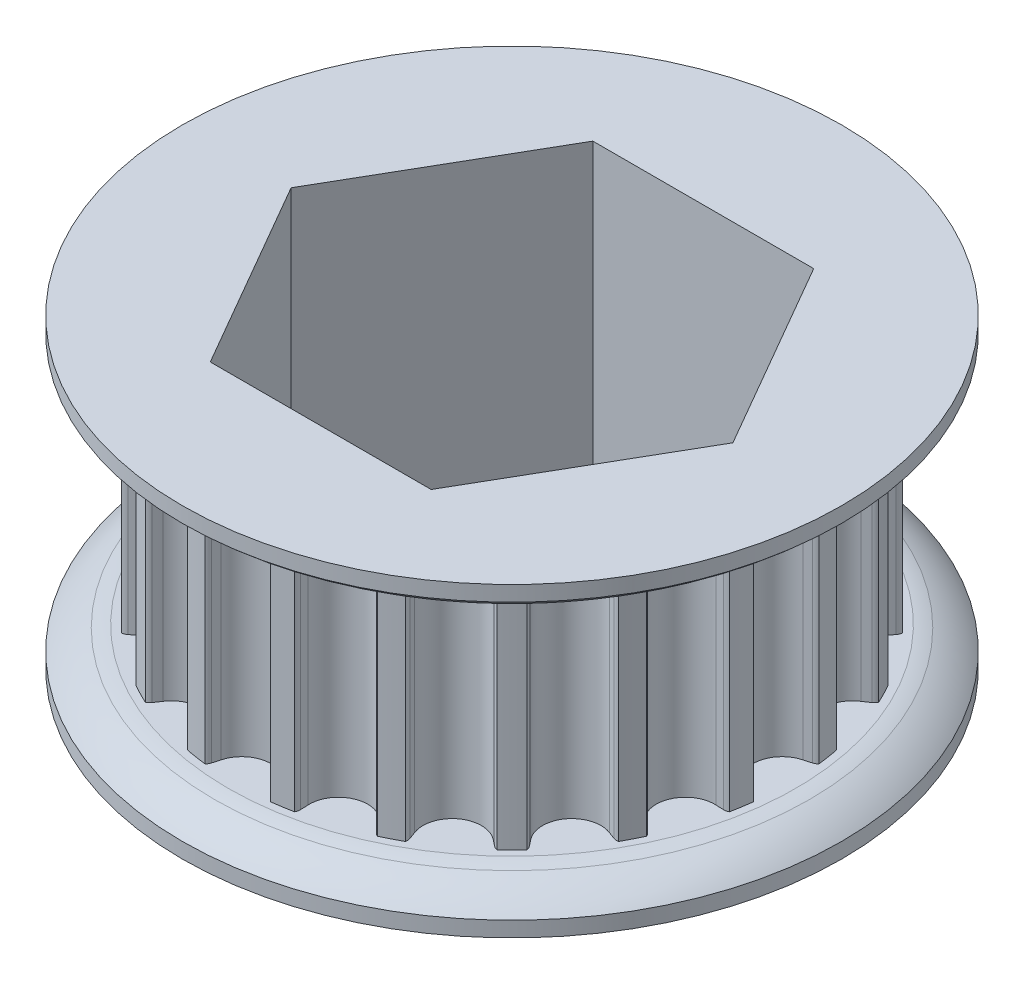
from build123d import *

# Parameters (mm, degrees)
SKETCH1_R          = 9.168296891
TOOTHOD_DEPTH      = 3.81
TOOTHPROFILE_DEPTH = 4.81
TOOTHPATTERN_COUNT = 20
BORE_DEPTH         = 6.08
BORE_DEPTH_BACK    = 6.08


with BuildPart() as part:
    # Sketch1 → ToothOD (new body, symmetric)
    with BuildSketch(Plane(origin=(0, 0, 0), x_dir=(1, 0, 0), z_dir=(0, 1, 0))):
        Circle(SKETCH1_R)
    extrude(amount=TOOTHOD_DEPTH, both=True)

    # Sketch2 → ToothProfile (cut, symmetric)
    with BuildSketch(Plane(origin=(0, 0, 0), x_dir=(1, 0, 0), z_dir=(0, 1, 0))):
        with BuildLine():
            ThreePointArc((-0.937033068, 8.718358887), (-0.590385173, 8.200184277), (0, 7.999896891))
            ThreePointArc((0, 7.999896891), (0.590385173, 8.200184277), (0.937033068, 8.718358887))
            ThreePointArc((0.937033068, 8.718358887), (0.971699064, 8.844470349), (1.007805813, 8.970176891))
            ThreePointArc((1.007805813, 8.970176891), (1.039709124, 9.042165511), (1.089260141, 9.10336093))
            ThreePointArc((1.089260141, 9.10336093), (0, 9.168296891), (-1.089260141, 9.10336093))
            ThreePointArc((-1.089260141, 9.10336093), (-1.039709124, 9.042165511), (-1.007805813, 8.970176891))
            ThreePointArc((-1.007805813, 8.970176891), (-0.971699064, 8.844470349), (-0.937033068, 8.718358887))
        make_face()
    toothprofile = extrude(amount=TOOTHPROFILE_DEPTH, both=True, mode=Mode.SUBTRACT)

    # ToothPattern: ToothProfile ×20 about axis
    toothpattern_axis = Axis((0, 0, 0), (0, 1, 0))
    for i in range(1, TOOTHPATTERN_COUNT):
        add(toothprofile.rotate(toothpattern_axis, i * 360 / TOOTHPATTERN_COUNT), mode=Mode.SUBTRACT)

    # Sketch4 → Flange (revolve)
    with BuildSketch(Plane.XY):
        with BuildLine():
            Line((0, -3.81), (9.422296891, -3.81))
            ThreePointArc((9.422296891, -3.81), (9.651943512, -3.845951298), (9.877369219, -3.902637424))
            ThreePointArc((9.877369219, -3.902637424), (10.445097796, -4.184197125), (10.946296891, -4.572))
            Line((10.946296891, -4.572), (10.946296891, -5.08))
            Line((10.946296891, -5.08), (0, -5.08))
            Line((0, -5.08), (0, -3.81))
        make_face()
        with BuildLine():
            Line((10.946296891, 5.08), (10.946296891, 4.572))
            ThreePointArc((10.946296891, 4.572), (10.445097796, 4.184197125), (9.877369219, 3.902637424))
            ThreePointArc((9.877369219, 3.902637424), (9.651943512, 3.845951298), (9.422296891, 3.81))
            Line((9.422296891, 3.81), (0, 3.81))
            Line((0, 3.81), (0, 5.08))
            Line((0, 5.08), (10.946296891, 5.08))
        make_face()
    revolve(axis=Axis((0, 8.73125, 0), (0, -1, 0)))

    # Sketch7 → Bore (cut, two sides)
    with BuildSketch(Plane.XZ) as bore_sk:
        Polygon((3.666174209, -6.35), (7.332348419, 0), (3.666174209, 6.35), (-3.666174209, 6.35), (-7.332348419, 0), (-3.666174209, -6.35), align=None)
    extrude(amount=BORE_DEPTH, mode=Mode.SUBTRACT)
    extrude(bore_sk.sketch, amount=-BORE_DEPTH_BACK, mode=Mode.SUBTRACT)


solid = part.part
